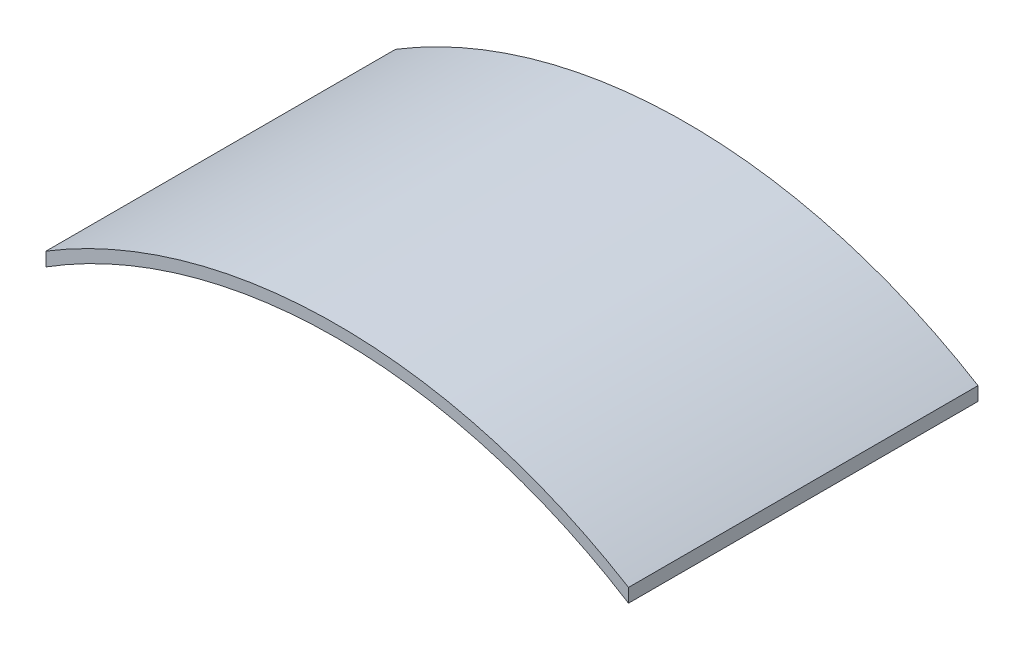
from build123d import *

# Parameters (mm, degrees)
BOSS_EXTRUDE2_DEPTH = 30
SKETCH13_W          = 29.120225156
SKETCH13_H          = 30
CUT_EXTRUDE1_DEPTH  = 157


with BuildPart() as part:
    # Sketch12 → Boss-Extrude2 (new body)
    with BuildSketch(Plane.XY):
        with BuildLine():
            Line((-48, 0), (-47, 0))
            ThreePointArc((-47, 0), (0, 47), (47, 0))
            Line((47, 0), (48, 0))
            ThreePointArc((48, 0), (0, 48), (-48, 0))
        make_face()
    extrude(amount=BOSS_EXTRUDE2_DEPTH)

    # Sketch13 → Cut-Extrude1 (cut)
    with BuildSketch(Plane(origin=(0, 60, 0), x_dir=(1, 0, 0), z_dir=(0, 1, 0))):
        with Locations((39.560112578, -15)):
            Rectangle(SKETCH13_W, SKETCH13_H)
        with Locations((-39.560112578, -15)):
            Rectangle(SKETCH13_W, SKETCH13_H)
    extrude(amount=-CUT_EXTRUDE1_DEPTH, mode=Mode.SUBTRACT)


solid = part.part
